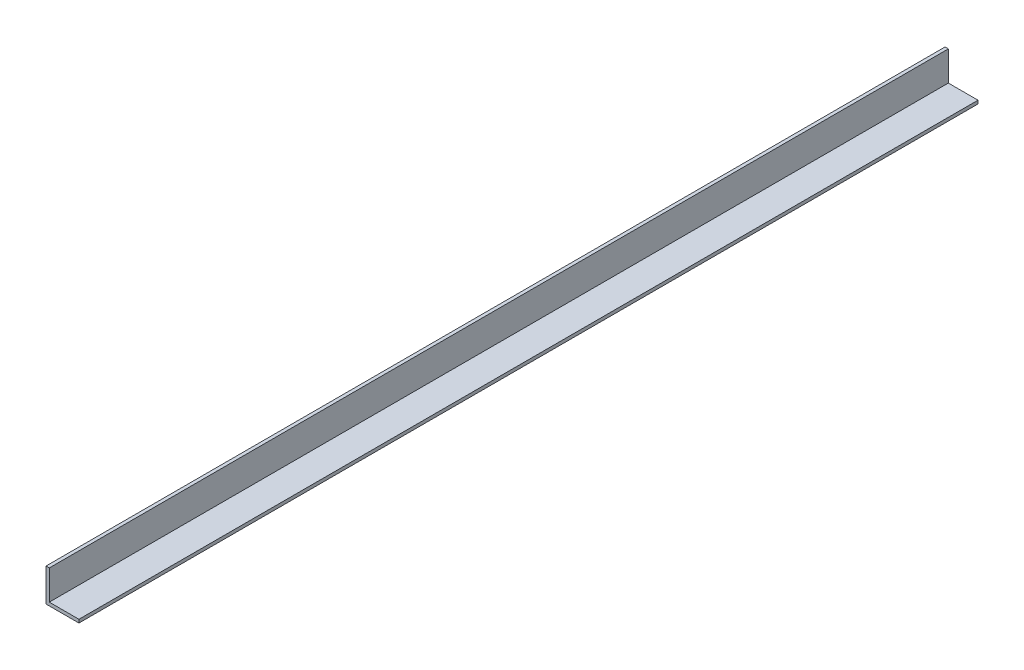
from build123d import *

# Parameters (mm, degrees)
BOSS_EXTRUDE1_DEPTH = 546


with BuildPart() as part:
    # Sketch1 → Boss-Extrude1 (new body)
    with BuildSketch(Plane.XY):
        Polygon((-12.500374185, 9.902439024), (-14.500374185, 9.902439024), (-14.500374185, -10.097560976), (5.499625815, -10.097560976), (5.499625815, -8.097560976), (-12.500374185, -8.097560976), align=None)
    extrude(amount=-BOSS_EXTRUDE1_DEPTH)


solid = part.part
